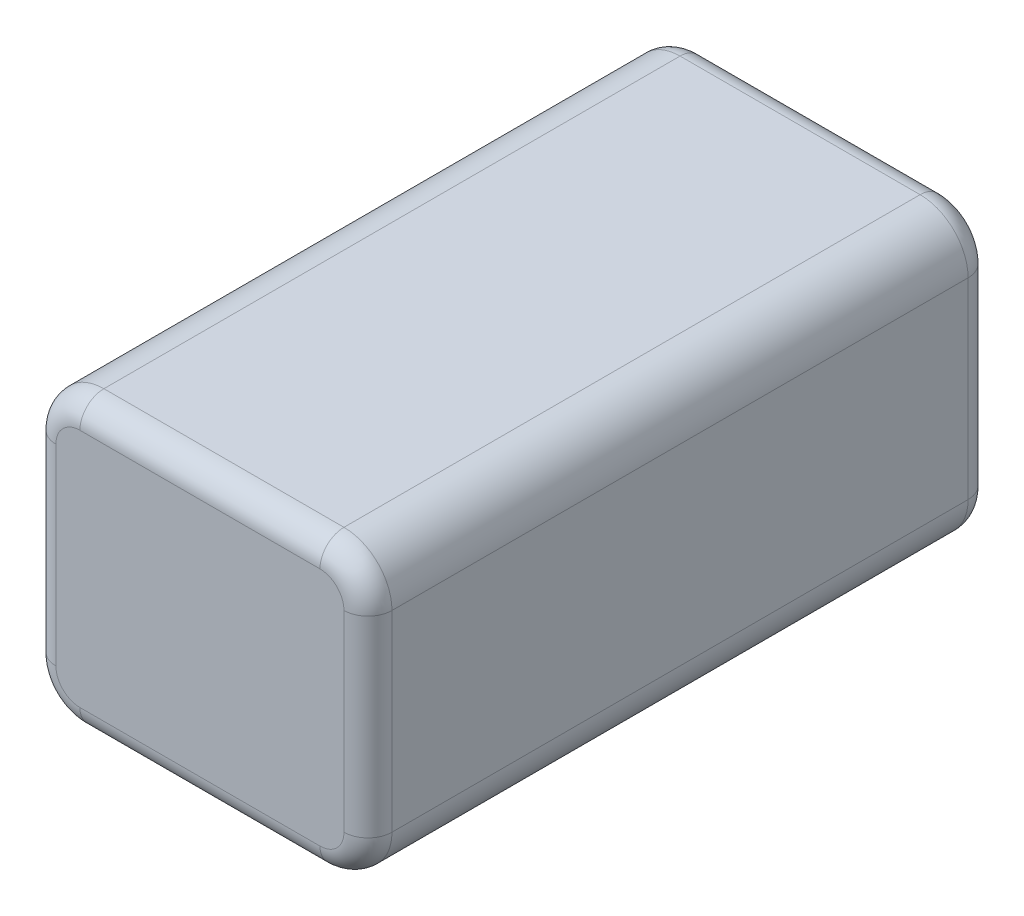
from build123d import *

# Parameters (mm, degrees)
BOSS_EXTRUDE1_DEPTH = 33.02
FILLET1_R           = 2.54


with BuildPart() as part:
    # Sketch1 → Boss-Extrude1 (new body, symmetric)
    with BuildSketch(Plane.XY):
        with BuildLine():
            Line((-12.7, -15.24), (12.7, -15.24))
            ThreePointArc((12.7, -15.24), (16.292102448, -13.752102448), (17.78, -10.16))
            Line((17.78, -10.16), (17.78, 10.16))
            ThreePointArc((17.78, 10.16), (16.292102448, 13.752102448), (12.7, 15.24))
            Line((12.7, 15.24), (-12.7, 15.24))
            ThreePointArc((-12.7, 15.24), (-16.292102448, 13.752102448), (-17.78, 10.16))
            Line((-17.78, 10.16), (-17.78, -10.16))
            ThreePointArc((-17.78, -10.16), (-16.292102448, -13.752102448), (-12.7, -15.24))
        make_face()
    extrude(amount=BOSS_EXTRUDE1_DEPTH, both=True)

    # Fillet1
    fillet1_edges = [part.edges().sort_by_distance(p)[0] for p in [
        (-16.292102448, 13.752102448, 33.02),
        (0, 15.24, -33.02),
        (16.292102448, 13.752102448, -33.02),
        (-17.78, 0, 33.02),
        (-16.292102448, -13.752102448, 33.02),
        (0, -15.24, 33.02),
        (16.292102448, -13.752102448, 33.02),
        (17.78, 0, 33.02),
        (16.292102448, 13.752102448, 33.02),
        (0, 15.24, 33.02),
        (17.78, 0, -33.02),
        (16.292102448, -13.752102448, -33.02),
        (0, -15.24, -33.02),
        (-16.292102448, -13.752102448, -33.02),
        (-17.78, 0, -33.02),
        (-16.292102448, 13.752102448, -33.02),
    ]]
    fillet(fillet1_edges, radius=FILLET1_R)


solid = part.part
